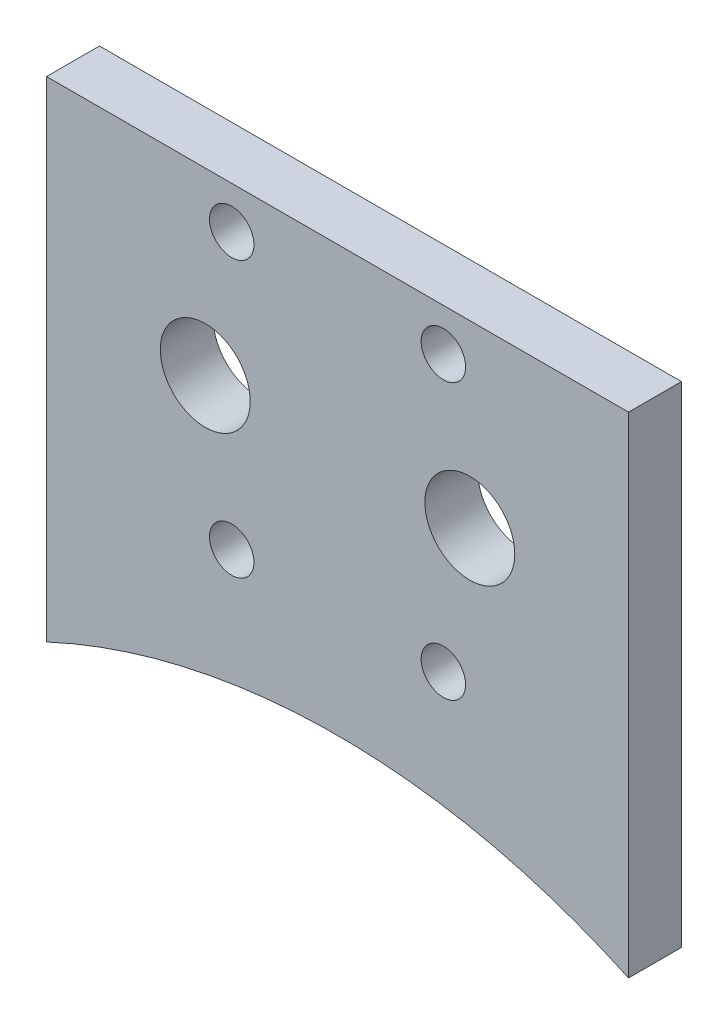
from build123d import *

# Parameters (mm, degrees)
SKETCH1_R           = 4.25
SKETCH1_R_2         = 2.1
BOSS_EXTRUDE1_DEPTH = 5
SKETCH2_W           = 23
SKETCH2_H           = 60
CUT_EXTRUDE1_DEPTH  = 10
FILLET1_R           = 5
FILLET2_R           = 5
CUT_EXTRUDE2_DEPTH  = 5


with BuildPart() as part:
    # Sketch1 → Boss-Extrude1 (new body)
    with BuildSketch(Plane.XY):
        with BuildLine():
            Line((-50.417601538, -29.831415105), (-27.417601538, -29.831415105))
            ThreePointArc((-27.417601538, -29.831415105), (0.082398462, -23.727510052), (27.582398462, -29.831415105))
            Line((27.582398462, -29.831415105), (50.582398462, -29.831415105))
            Line((50.582398462, -29.831415105), (50.582398462, 25.168584895))
            ThreePointArc((50.582398462, 25.168584895), (49.117932367, 28.704118801), (45.582398462, 30.168584895))
            Line((45.582398462, 30.168584895), (-45.417601538, 30.168584895))
            ThreePointArc((-45.417601538, 30.168584895), (-48.953135444, 28.704118801), (-50.417601538, 25.168584895))
            Line((-50.417601538, 25.168584895), (-50.417601538, -29.831415105))
        make_face()
        with Locations((12.582398462, -0.519851907)):
            Circle(SKETCH1_R, mode=Mode.SUBTRACT)
        with Locations((10.082398462, -13.519851907)):
            Circle(SKETCH1_R_2, mode=Mode.SUBTRACT)
        with Locations((-9.917601538, -13.519851907)):
            Circle(SKETCH1_R_2, mode=Mode.SUBTRACT)
        with Locations((-12.417601538, -0.519851907)):
            Circle(SKETCH1_R, mode=Mode.SUBTRACT)
        with Locations((-9.917601538, 12.480148093)):
            Circle(SKETCH1_R_2, mode=Mode.SUBTRACT)
        with Locations((10.082398462, 12.480148093)):
            Circle(SKETCH1_R_2, mode=Mode.SUBTRACT)
    extrude(amount=BOSS_EXTRUDE1_DEPTH)

    # Sketch2 → Cut-Extrude1 (cut)
    with BuildSketch(Plane.XY.offset(5)):
        with Locations((-38.917601538, 0.168584895)):
            Rectangle(SKETCH2_W, SKETCH2_H)
        with Locations((39.082398462, 0.168584895)):
            Rectangle(SKETCH2_W, SKETCH2_H)
    extrude(amount=-CUT_EXTRUDE1_DEPTH, mode=Mode.SUBTRACT)

    # Fillet1
    fillet1_edges = [part.edges().sort_by_distance(p)[0] for p in [
        (27.582398462, 30.168584895, 2.5),
    ]]
    fillet(fillet1_edges, radius=FILLET1_R)

    # Fillet2
    fillet2_edges = [part.edges().sort_by_distance(p)[0] for p in [
        (-27.417601538, 30.168584895, 2.5),
    ]]
    fillet(fillet2_edges, radius=FILLET2_R)

    # Sketch3 → Cut-Extrude2 (cut)
    with BuildSketch(Plane(origin=(0, 0, 0), x_dir=(-1, 0, 0), z_dir=(0, 0, -1))):
        with BuildLine():
            Line((-27.582398462, 25.168584895), (-27.582398462, 16.480148093))
            Line((-27.582398462, 16.480148093), (27.417601538, 16.444815638))
            Line((27.417601538, 16.444815638), (27.417601538, 25.168584895))
            ThreePointArc((27.417601538, 25.168584895), (25.953135444, 28.704118801), (22.417601538, 30.168584895))
            Line((22.417601538, 30.168584895), (-22.582398462, 30.168584895))
            ThreePointArc((-22.582398462, 30.168584895), (-26.117932367, 28.704118801), (-27.582398462, 25.168584895))
        make_face()
    extrude(amount=-CUT_EXTRUDE2_DEPTH, mode=Mode.SUBTRACT)


solid = part.part
